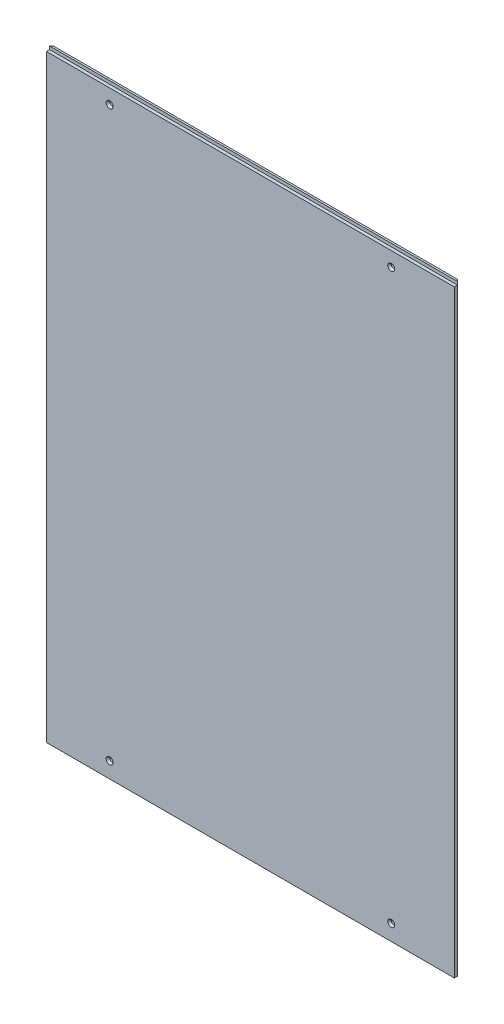
from build123d import *

# Parameters (mm, degrees)
SKETCH1_W           = 646
SKETCH1_H           = 953
BOSS_EXTRUDE1_DEPTH = 8
CHAMFER1_SIZE       = 3
SKETCH3_R           = 2.5
CUT_EXTRUDE2_DEPTH  = 9
CHAMFER2_SIZE       = 3
SKETCH2_W           = 646
SKETCH2_H           = 5
CUT_EXTRUDE3_DEPTH  = 5


with BuildPart() as part:
    # Sketch1 → Boss-Extrude1 (new body)
    with BuildSketch(Plane.XY):
        Rectangle(SKETCH1_W, SKETCH1_H)
    extrude(amount=BOSS_EXTRUDE1_DEPTH)

    # Chamfer1
    chamfer1_edges = [part.edges().sort_by_distance(p)[0] for p in [
        (-323, 0, 0),
        (323, 0, 0),
    ]]
    chamfer(chamfer1_edges, length=CHAMFER1_SIZE)

    # Sketch3 → Cut-Extrude2 (cut, through all)
    with BuildSketch(Plane.XY.offset(8)):
        with Locations((-223, 448.5)):
            Circle(SKETCH3_R)
        with Locations((-223, -451.5)):
            Circle(SKETCH3_R)
        with Locations((223, -451.5)):
            Circle(SKETCH3_R)
        with Locations((223, 448.5)):
            Circle(SKETCH3_R)
    extrude(amount=-CUT_EXTRUDE2_DEPTH, mode=Mode.SUBTRACT)

    # Chamfer2
    chamfer2_edges = [part.edges().sort_by_distance(p)[0] for p in [
        (-225.5, 448.5, 8),
        (-225.5, -451.5, 8),
        (220.5, -451.5, 8),
        (220.5, 448.5, 8),
    ]]
    chamfer(chamfer2_edges, length=CHAMFER2_SIZE)

    # Sketch2 → Cut-Extrude3 (cut)
    with BuildSketch(Plane.XY.offset(8)):
        with Locations((0, 474)):
            Rectangle(SKETCH2_W, SKETCH2_H)
    extrude(amount=-CUT_EXTRUDE3_DEPTH, mode=Mode.SUBTRACT)


solid = part.part
